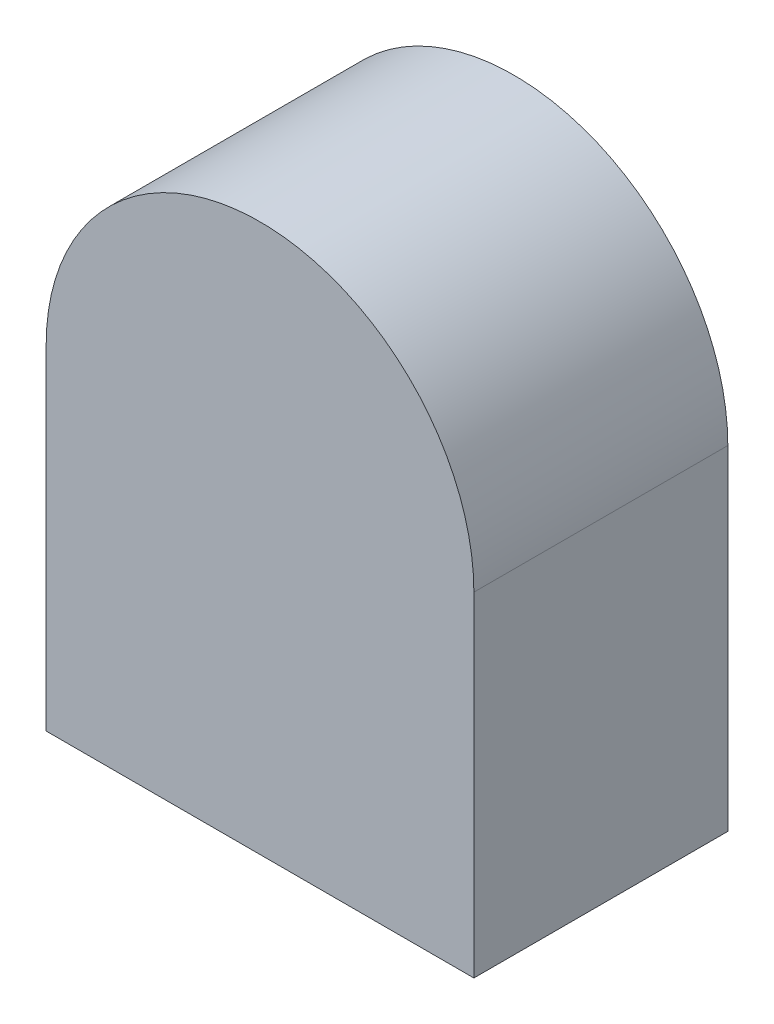
from build123d import *

# Parameters (mm, degrees)
EXTRUDE_1_DEPTH     = 19
SKETCH_2_R          = 5
CUT_EXTRUDE_1_DEPTH = 2
SKETCH_3_R          = 1.5
CUT_EXTRUDE_2_DEPTH = 10


with BuildPart() as part:
    # 草圖1 → 填料-伸長1 (new body)
    with BuildSketch(Plane.XY):
        with BuildLine():
            Line((-16, 0), (-16, -25))
            Line((-16, -25), (16, -25))
            Line((16, -25), (16, 0))
            ThreePointArc((16, 0), (0, 16), (-16, 0))
        make_face()
    extrude(amount=EXTRUDE_1_DEPTH)

    # 草圖2 → 除料-伸長1 (cut)
    with BuildSketch(Plane(origin=(0, 0, 0), x_dir=(-1, 0, 0), z_dir=(0, 0, -1))):
        Circle(SKETCH_2_R)
    extrude(amount=-CUT_EXTRUDE_1_DEPTH, mode=Mode.SUBTRACT)

    # 草圖3 → 除料-伸長2 (cut)
    with BuildSketch(Plane(origin=(0, 0, 2), x_dir=(-1, 0, 0), z_dir=(0, 0, -1))):
        Circle(SKETCH_3_R)
    extrude(amount=-CUT_EXTRUDE_2_DEPTH, mode=Mode.SUBTRACT)


solid = part.part
